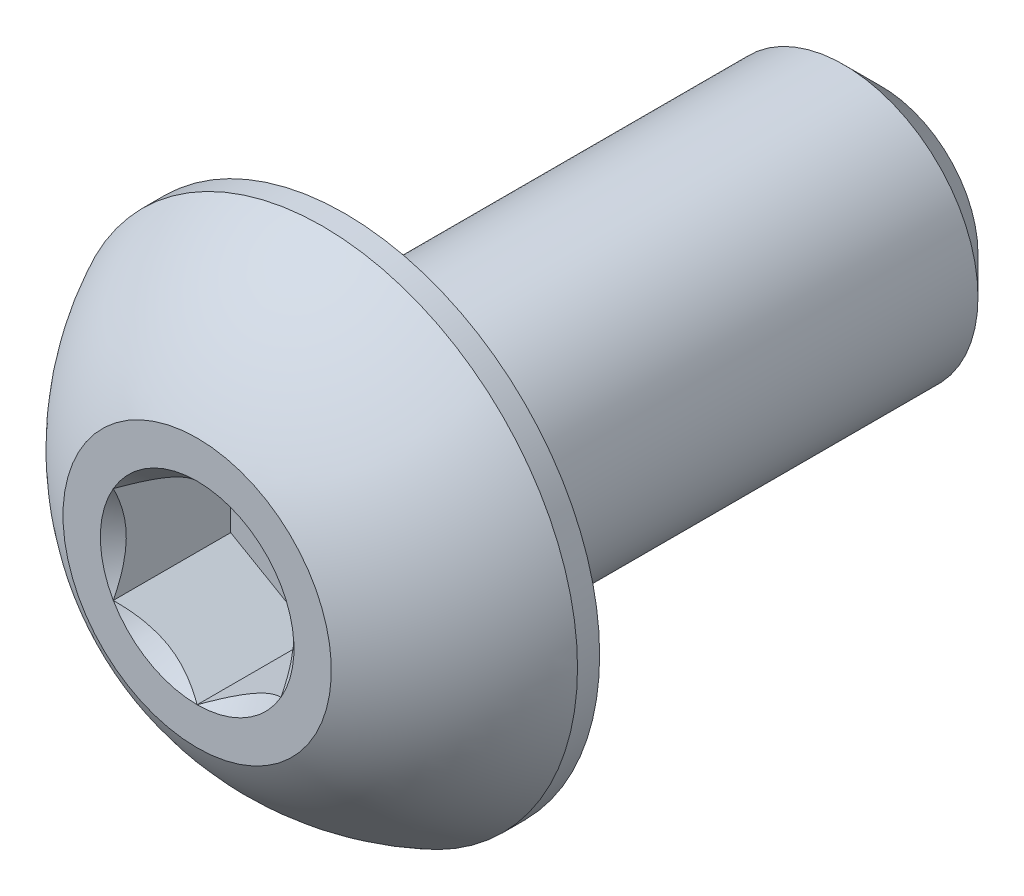
from build123d import *

# Parameters (mm, degrees)
CUT_EXTRUDE1_DEPTH = 1.75


with BuildPart() as part:
    # Sketch2 → Revolve1 (revolve)
    with BuildSketch(Plane(origin=(0, 0, 0), x_dir=(0, 0, -1), z_dir=(1, 0, 0)), mode=Mode.PRIVATE) as revolve1_sk:
        with BuildLine():
            Line((-5.1, 0), (5.1, 0))
            Line((5.1, 0), (5.1, 1.44))
            Line((5.1, 1.44), (4.54, 2))
            Line((4.54, 2), (-2.9, 2))
            Line((-2.9, 2), (-2.9, 3.8))
            Line((-2.9, 3.8), (-3.23, 3.8))
            ThreePointArc((-3.23, 3.8), (-4.306499853, 3.047002626), (-5.1, 2))
            Line((-5.1, 2), (-5.1, 0))
        make_face()
    revolve(revolve1_sk.sketch.rotate(Axis((0, 0, 5.1), (0, 0, -1)), 90), axis=Axis((0, 0, 5.1), (0, 0, -1)))

    # Sketch3 → Cut-Extrude1 (cut)
    with BuildSketch(Plane.XY.offset(5.1)):
        Polygon((0, 1.443375673), (-1.25, 0.721687836), (-1.25, -0.721687836), (0, -1.443375673), (1.25, -0.721687836), (1.25, 0.721687836), align=None)
    extrude(amount=-CUT_EXTRUDE1_DEPTH, mode=Mode.SUBTRACT)

    # Cut-Extrude2 cone 1 section (through the dimple's axis) → Cut-Extrude2 (revolve, cut)
    with BuildSketch(Plane(origin=(0, 0, 5.1), x_dir=(0, -1, 0), z_dir=(1, 0, 0))):
        Polygon((0, 0), (1.443375673, 0), (0, 1.443375673), align=None)
    revolve(axis=Axis((0, 0, 5.1), (0, 0, -1)), mode=Mode.SUBTRACT)


solid = part.part
